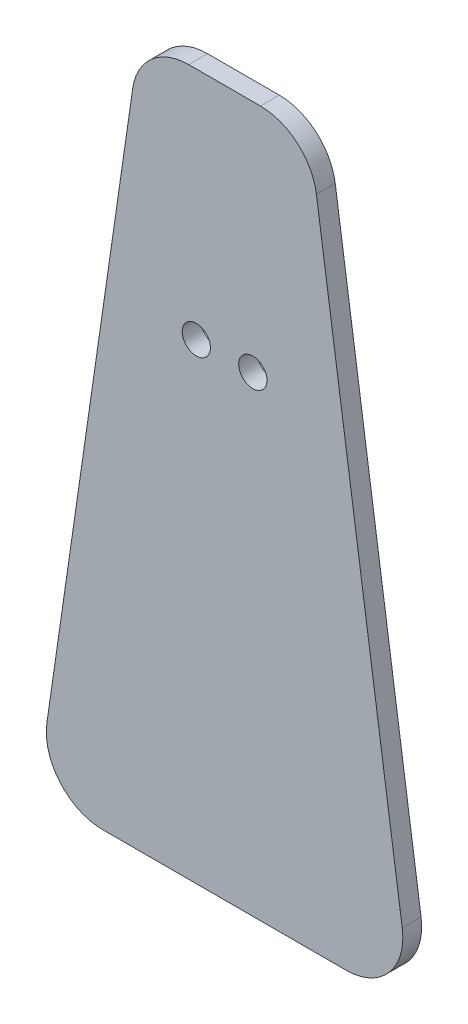
from build123d import *

# Parameters (mm, degrees)
SKETCH_1_R      = 1.5
EXTRUDE_1_DEPTH = 2


with BuildPart() as part:
    # 草图1 → 凸台-拉伸1 (new body)
    with BuildSketch(Plane.XY):
        with BuildLine():
            Line((-12.91723747, 0), (12.91723747, 0))
            ThreePointArc((12.91723747, 0), (17.453878353, 2.073310619), (18.855230664, 6.860370167))
            Line((18.855230664, 6.860370167), (9.744693373, 69.738315612))
            ThreePointArc((9.744693373, 69.738315612), (7.73338956, 73.414586328), (3.806700178, 74.877945445))
            Line((3.806700178, 74.877945445), (0, 74.877945445))
            Line((0, 74.877945445), (-3.806700178, 74.877945445))
            ThreePointArc((-3.806700178, 74.877945445), (-7.73338956, 73.414586328), (-9.744693373, 69.738315612))
            Line((-9.744693373, 69.738315612), (-18.855230664, 6.860370167))
            ThreePointArc((-18.855230664, 6.860370167), (-17.453878353, 2.073310619), (-12.91723747, 0))
        make_face()
        with Locations((-3, 50)):
            Circle(SKETCH_1_R, mode=Mode.SUBTRACT)
        with Locations((3, 50)):
            Circle(SKETCH_1_R, mode=Mode.SUBTRACT)
    extrude(amount=EXTRUDE_1_DEPTH)


solid = part.part
